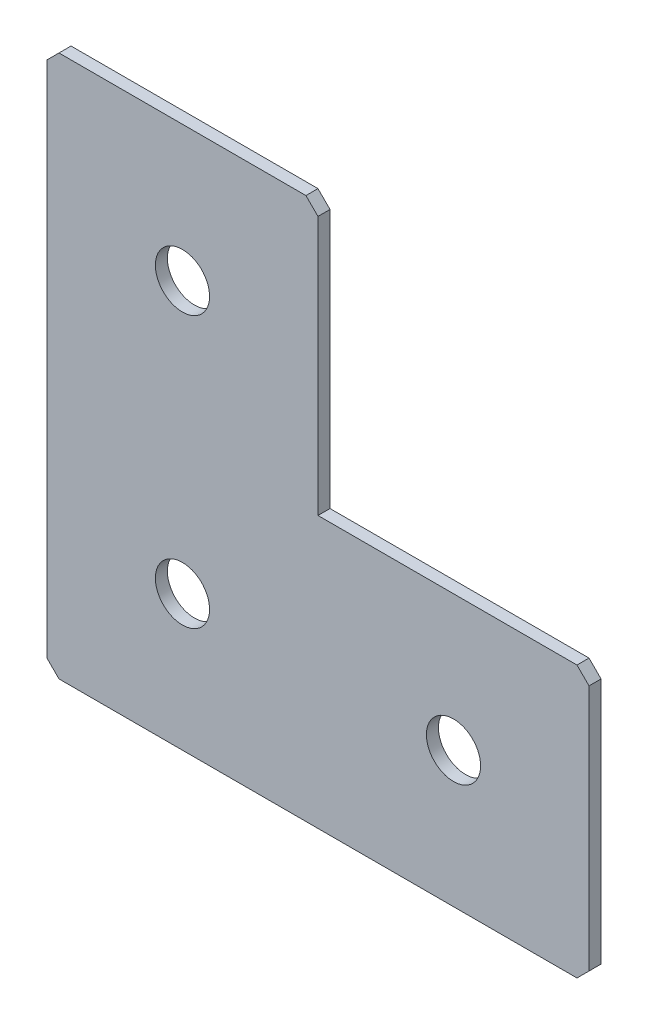
from build123d import *

# Parameters (mm, degrees)
EXTRUDE_1_DEPTH   = 2
HOLE_WIZARD_M81_D = 9
CHAMFER_1_SIZE    = 2


with BuildPart() as part:
    # Эскиз1 → Бобышка-Вытянуть1 (new body)
    with BuildSketch(Plane(origin=(0, 0, 0), x_dir=(1, 0, 0), z_dir=(0, 0, -1))):
        Polygon((0, 0), (0, 90), (90, 90), (90, 45), (45, 45), (45, 0), align=None)
    extrude(amount=EXTRUDE_1_DEPTH)

    # Отверстие с зазором M81 (through all)
    with Locations(Plane(origin=(0, 0, -2), x_dir=(1, 0, 0), z_dir=(0, 0, -1))):
        with Locations((22.5, 67.5), (22.5, 22.5), (67.5, 67.5)):
            Hole(HOLE_WIZARD_M81_D / 2)

    # Фаска1
    chamfer_1_edges = [part.edges().sort_by_distance(p)[0] for p in [
        (0, 0, -1),
        (0, -90, -1),
        (90, -90, -1),
        (90, -45, -1),
        (45, 0, -1),
    ]]
    chamfer(chamfer_1_edges, length=CHAMFER_1_SIZE)


solid = part.part
